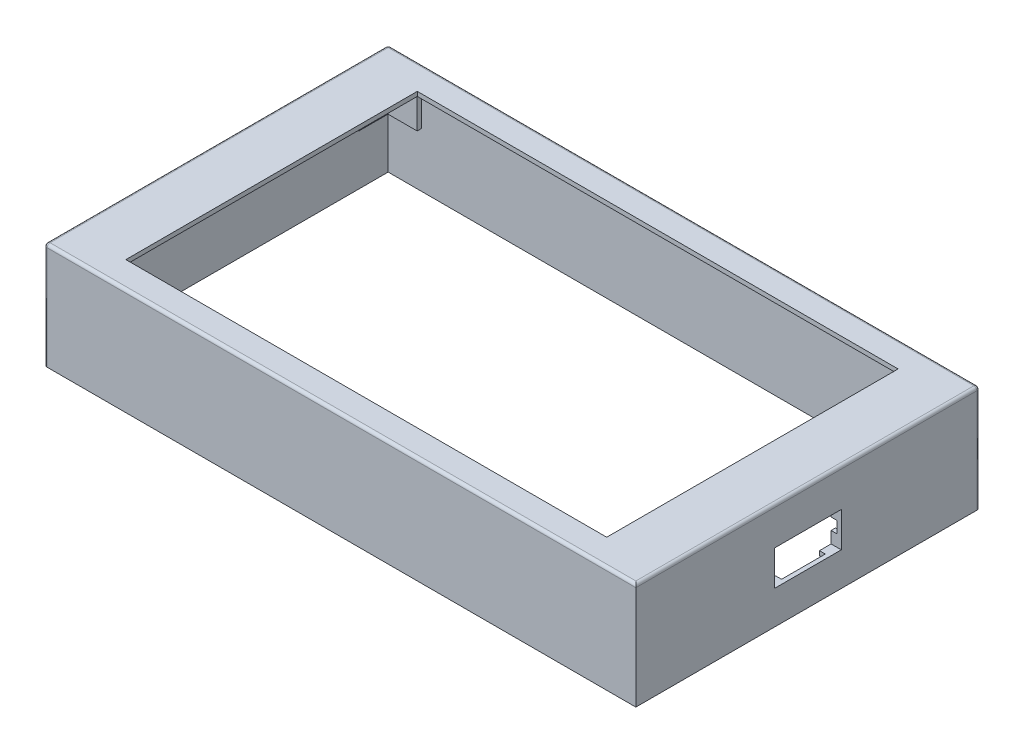
from build123d import *

# Parameters (mm, degrees)
SKETCH_1_W          = 200
SKETCH_1_H          = 115
F_35MM_DEPTH        = 35
SHELL_3_T           = 1.5
SKETCH_2_W          = 165
SKETCH_2_H          = 100
CUT_EXTRUDE_7_DEPTH = 1.5
SKETCH_3_W          = 16
SKETCH_3_H          = 10
CUT_EXTRUDE_8_DEPTH = 1.5
SKETCH_4_W          = 23
SKETCH_4_H          = 12
CUT_EXTRUDE_9_DEPTH = 1.5
EXTRUDE_1_DEPTH     = 13
EXTRUDE_2_DEPTH     = 2
FILLET_2_R          = 1


with BuildPart() as part:
    # 草图1 → 凸台-拉伸35mm (new body)
    with BuildSketch(Plane(origin=(0, 0, 0), x_dir=(1, 0, 0), z_dir=(0, 1, 0))):
        Rectangle(SKETCH_1_W, SKETCH_1_H)
    extrude(amount=F_35MM_DEPTH)

    # 抽壳3
    shell_3_openings = [part.faces().sort_by_distance(p)[0] for p in [
        (0, 0, 0),
    ]]
    offset(amount=SHELL_3_T, openings=shell_3_openings, kind=Kind.INTERSECTION)

    # 草图2 → 切除-拉伸7 (cut)
    with BuildSketch(Plane(origin=(0, 35, 0), x_dir=(1, 0, 0), z_dir=(0, 1, 0))):
        Rectangle(SKETCH_2_W, SKETCH_2_H)
    extrude(amount=CUT_EXTRUDE_7_DEPTH, mode=Mode.SUBTRACT)

    # 草图3 → 切除-拉伸8 (cut)
    with BuildSketch(Plane(origin=(-100, 0, 0), x_dir=(0, 0, -1), z_dir=(1, 0, 0))):
        with Locations((12, 22.5)):
            Rectangle(SKETCH_3_W, SKETCH_3_H)
    extrude(amount=-CUT_EXTRUDE_8_DEPTH, mode=Mode.SUBTRACT)

    # 草图4 → 切除-拉伸9 (cut)
    with BuildSketch(Plane.ZY.offset(-100)):
        with Locations((0, 17.5)):
            Rectangle(SKETCH_4_W, SKETCH_4_H)
    extrude(amount=-CUT_EXTRUDE_9_DEPTH, mode=Mode.SUBTRACT)

    # 草图6 → 凸台-拉伸1 (add)
    with BuildSketch(Plane(origin=(0, 35, 0), x_dir=(-1, 0, 0), z_dir=(0, -1, 0))):
        Polygon((-95.25, 52.7), (-85.25, 52.7), (-85.25, 54.2), (-96.75, 54.2), (-96.75, 42.7), (-95.25, 42.7), align=None)
        Polygon((-96.75, -42.7), (-95.25, -42.7), (-95.25, -52.7), (-85.25, -52.7), (-85.25, -54.2), (-96.75, -54.2), align=None)
        Polygon((85.25, -52.7), (85.25, -54.2), (96.75, -54.2), (96.75, -42.7), (95.25, -42.7), (95.25, -52.7), align=None)
        Polygon((85.25, 52.7), (85.25, 54.2), (96.75, 54.2), (96.75, 42.7), (95.25, 42.7), (95.25, 52.7), align=None)
    extrude(amount=EXTRUDE_1_DEPTH)

    # 草图7 → 凸台-拉伸2 (add)
    with BuildSketch(Plane.ZY.offset(-100)):
        Polygon((13, 15.5), (11.5, 15.5), (11.5, 11.5), (7.5, 11.5), (7.5, 10), (13, 10), align=None)
        Polygon((-7.5, 23.5), (-7.5, 25), (-13, 25), (-13, 19.5), (-11.5, 19.5), (-11.5, 23.5), align=None)
        Polygon((7.5, 23.5), (7.5, 25), (13, 25), (13, 19.5), (11.5, 19.5), (11.5, 23.5), align=None)
        Polygon((-7.5, 11.5), (-7.5, 10), (-13, 10), (-13, 15.5), (-11.5, 15.5), (-11.5, 11.5), align=None)
    extrude(amount=EXTRUDE_2_DEPTH)

    # 圆角2
    fillet_2_edges = [part.edges().sort_by_distance(p)[0] for p in [
        (101.5, 36.5, 0),
        (0, 36.5, -59),
        (100, 17.5, 57.5),
        (-101.5, 36.5, 0),
        (-101.5, 18.25, -59),
        (101.5, 18.25, -59),
        (-101.5, 18.25, 59),
        (0, 36.5, 59),
    ]]
    fillet(fillet_2_edges, radius=FILLET_2_R)


solid = part.part
